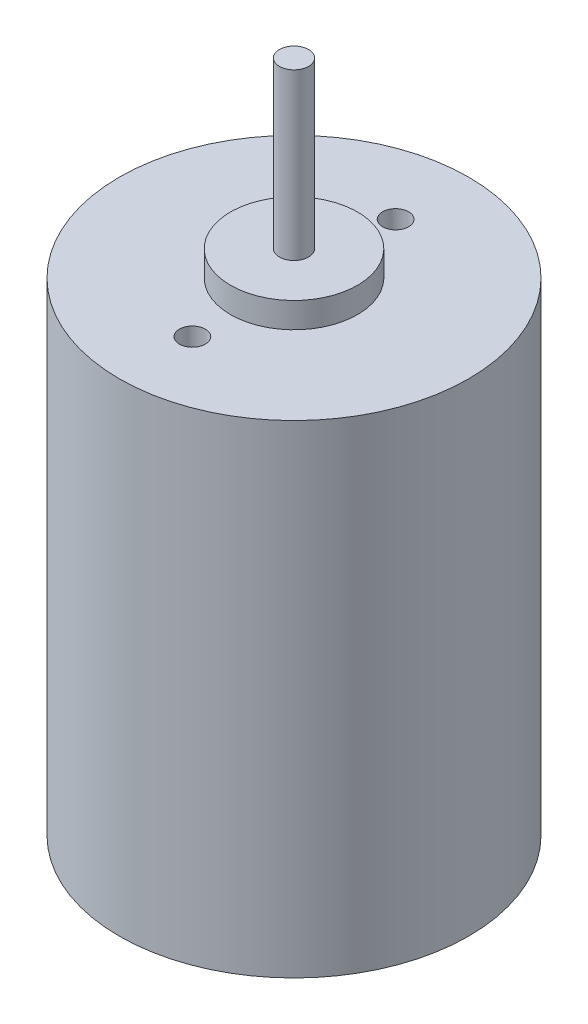
from build123d import *

# Parameters (mm, degrees)
SKETCH_1_R               = 13.75
EXTRUDE_1_DEPTH          = 38
SKETCH_2_R               = 5
EXTRUDE_2_DEPTH          = 2
SKETCH_3_R               = 1.15
EXTRUDE_3_DEPTH          = 13
HOLE_WIZARD_M2_5_1_D     = 2.05
HOLE_WIZARD_M2_5_1_DEPTH = 3.75
HOLE_WIZARD_M2_5_1_TIP   = 0.615882135


with BuildPart() as part:
    # 草图1 → 凸台-拉伸1 (new body)
    with BuildSketch(Plane(origin=(0, 0, 0), x_dir=(1, 0, 0), z_dir=(0, 1, 0))):
        Circle(SKETCH_1_R)
    extrude(amount=EXTRUDE_1_DEPTH)

    # 草图2 → 凸台-拉伸2 (add)
    with BuildSketch(Plane(origin=(0, 38, 0), x_dir=(1, 0, 0), z_dir=(0, 1, 0))):
        Circle(SKETCH_2_R)
    extrude(amount=EXTRUDE_2_DEPTH)

    # 草图3 → 凸台-拉伸3 (add)
    with BuildSketch(Plane(origin=(0, 40, 0), x_dir=(1, 0, 0), z_dir=(0, 1, 0))):
        Circle(SKETCH_3_R)
    extrude(amount=EXTRUDE_3_DEPTH)

    # M2.5 螺纹孔1
    with Locations(Plane(origin=(0, 38, 0), x_dir=(1, 0, 0), z_dir=(0, 1, 0))):
        with Locations((0, 8), (0, -8)):
            Hole(HOLE_WIZARD_M2_5_1_D / 2, depth=HOLE_WIZARD_M2_5_1_DEPTH)
            with Locations((0, 0, -(HOLE_WIZARD_M2_5_1_DEPTH + HOLE_WIZARD_M2_5_1_TIP / 2))):  # 118° drill point
                Cone(0, HOLE_WIZARD_M2_5_1_D / 2, HOLE_WIZARD_M2_5_1_TIP, mode=Mode.SUBTRACT)


solid = part.part
